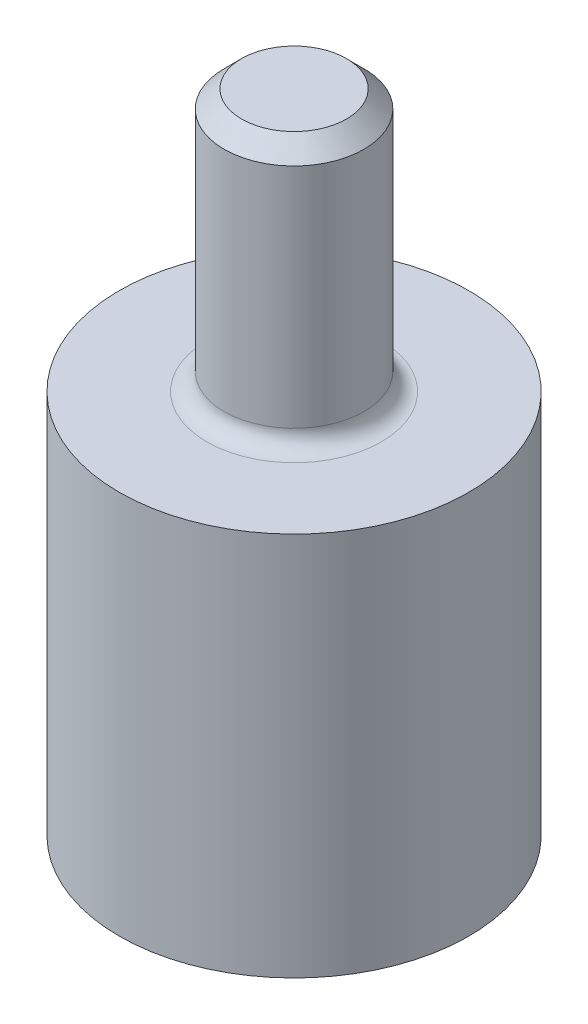
from build123d import *

# Parameters (mm, degrees)
SKETCH_1_R          = 10
EXTRUDE_1_DEPTH     = 22
SKETCH_2_R          = 4
EXTRUDE_2_DEPTH     = 15
FILLET_1_R          = 1
CHAMFER_1_SIZE      = 1
SKETCH_4_R          = 3
CUT_EXTRUDE_1_DEPTH = 16
SKETCH_3_R          = 1.35
CUT_EXTRUDE_2_DEPTH = 10
SKETCH_5_R          = 1.35
CUT_EXTRUDE_3_DEPTH = 10


with BuildPart() as part:
    # 草图1 → 凸台-拉伸1 (new body)
    with BuildSketch(Plane(origin=(0, 0, 0), x_dir=(1, 0, 0), z_dir=(0, 1, 0))):
        Circle(SKETCH_1_R)
    extrude(amount=EXTRUDE_1_DEPTH)

    # 草图2 → 凸台-拉伸2 (add)
    with BuildSketch(Plane(origin=(0, 22, 0), x_dir=(1, 0, 0), z_dir=(0, 1, 0))):
        Circle(SKETCH_2_R)
    extrude(amount=EXTRUDE_2_DEPTH)

    # 圆角1
    fillet_1_edges = [part.edges().sort_by_distance(p)[0] for p in [
        (-4, 22, 0),
    ]]
    fillet(fillet_1_edges, radius=FILLET_1_R)

    # 倒角1
    chamfer_1_edges = [part.edges().sort_by_distance(p)[0] for p in [
        (-4, 37, 0),
    ]]
    chamfer(chamfer_1_edges, length=CHAMFER_1_SIZE)

    # 草图4 → 切除-拉伸1 (cut)
    with BuildSketch(Plane.XZ):
        Circle(SKETCH_4_R)
    extrude(amount=-CUT_EXTRUDE_1_DEPTH, mode=Mode.SUBTRACT)

    # 草图3 → 切除-拉伸2 (cut)
    with BuildSketch(Plane.XY):
        with Locations((0, 4)):
            Circle(SKETCH_3_R)
    extrude(amount=-CUT_EXTRUDE_2_DEPTH, mode=Mode.SUBTRACT)

    # 草图5 → 切除-拉伸3 (cut)
    with BuildSketch(Plane(origin=(0, 0, 0), x_dir=(0, 0, -1), z_dir=(1, 0, 0))):
        with Locations((0, 4)):
            Circle(SKETCH_5_R)
    extrude(amount=-CUT_EXTRUDE_3_DEPTH, mode=Mode.SUBTRACT)


solid = part.part
